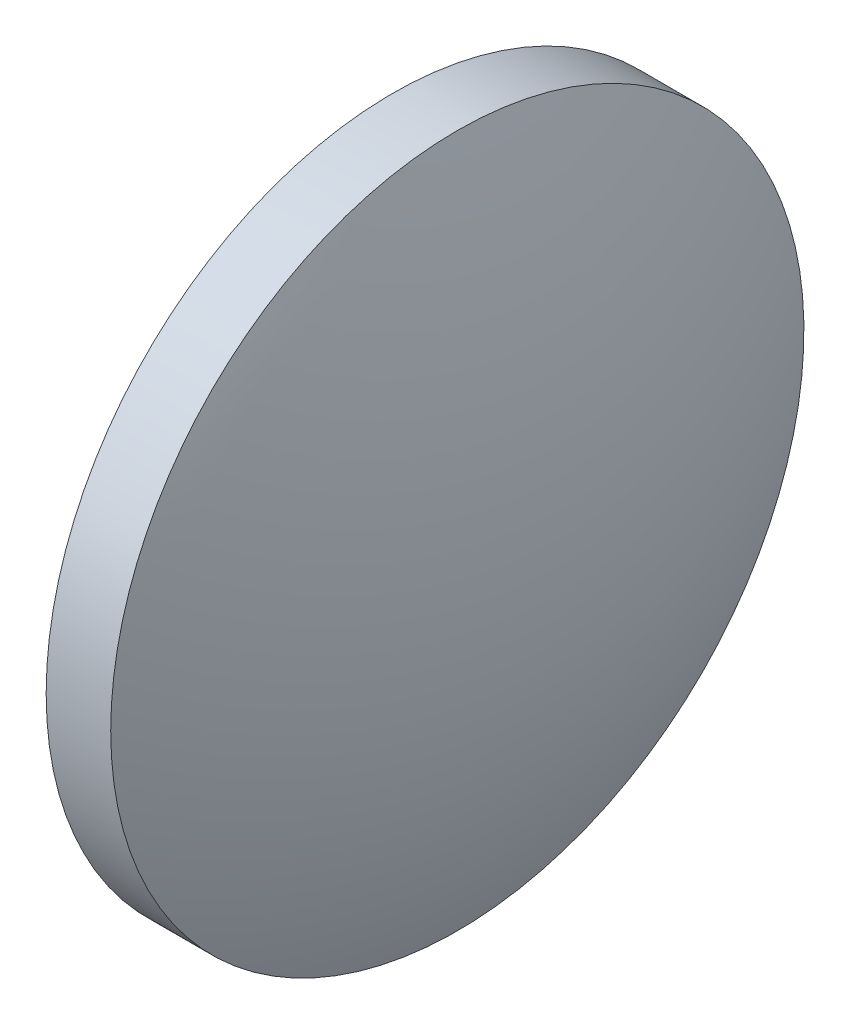
from build123d import *


with BuildPart() as part:
    # 草图1 → 旋转1 (revolve)
    with BuildSketch(Plane.XY):
        with BuildLine():
            Line((440.271278024, 0.76815575), (440.271278024, 8.76815575))
            Line((440.271278024, 8.76815575), (441.761278024, 8.76815575))
            ThreePointArc((441.761278024, 8.76815575), (442.964783054, 4.848354887), (443.371278024, 0.76815575))
            Line((443.371278024, 0.76815575), (440.271278024, 0.76815575))
        make_face()
    revolve(axis=Axis((438.623305551, 0.76815575, 0), (1, 0, 0)))


solid = part.part
